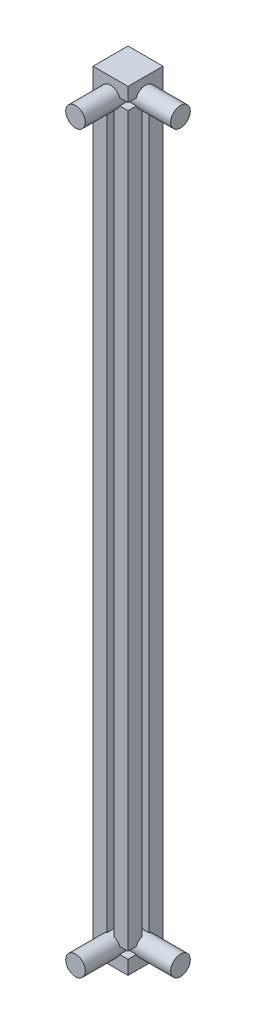
from build123d import *

# Parameters (mm, degrees)
CROQUIS2_W                   = 220
CROQUIS2_H                   = 220
CROQUIS2_W_2                 = 200
CROQUIS2_H_2                 = 200
SALIENTE_EXTRUIR1_DEPTH      = 10
CROQUIS3_W                   = 212
CROQUIS3_H                   = 212
CROQUIS3_W_2                 = 210
CROQUIS3_H_2                 = 210
CROQUIS3_W_3                 = 208
CROQUIS3_H_3                 = 208
CORTAR_EXTRUIR1_DEPTH        = 3.5
CROQUIS4_W                   = 10
CROQUIS4_H                   = 10
SALIENTE_EXTRUIR2_DEPTH      = 200
SALIENTE_EXTRUIR2_DEPTH_BACK = 10
CROQUIS6_W                   = 3.5
CROQUIS6_H                   = 2
CROQUIS6_W_2                 = 2
CROQUIS6_H_2                 = 3.5
CROQUIS6_W_3                 = 1.99805467
CORTAR_EXTRUIR2_DEPTH        = 203.5
CROQUIS7_W                   = 220
CROQUIS7_H                   = 220
CROQUIS7_W_2                 = 200
CROQUIS7_H_2                 = 200
SALIENTE_EXTRUIR3_DEPTH      = 10
CORTAR_EXTRUIR3_START        = -3.5
CROQUIS8_W                   = 207
CROQUIS8_H                   = 2
CORTAR_EXTRUIR3_DEPTH        = 207
MATRIZC1_COUNT               = 4
CROQUIS9_W                   = 86
CROQUIS9_H                   = 16
BRAZOS_DEPTH                 = 10
MATRIZC2_COUNT               = 4
CROQUIS10_W                  = 237.555255491
CROQUIS10_H                  = 247.362549521
CORTAR_EXTRUIR4_DEPTH        = 221
CROQUIS11_W                  = 253.49457107
CROQUIS11_H                  = 258.277976667
CORTAR_EXTRUIR5_DEPTH        = 11
SALIENTE_EXTRUIR4_START      = -6
CROQUIS12_R                  = 2.8
SALIENTE_EXTRUIR4_DEPTH      = 16
CROQUIS13_R                  = 2.8
SALIENTE_EXTRUIR5_DEPTH      = 10
SALIENTE_EXTRUIR5_DEPTH_BACK = 10


with BuildPart() as part:
    # Croquis2 → Saliente-Extruir1 (new body)
    with BuildSketch(Plane.XY):
        with Locations((110, -110)):
            Rectangle(CROQUIS2_W, CROQUIS2_H)
        with Locations((110, -110)):
            Rectangle(CROQUIS2_W_2, CROQUIS2_H_2, mode=Mode.SUBTRACT)
    extrude(amount=SALIENTE_EXTRUIR1_DEPTH)

    # Croquis3 → Cortar-Extruir1 (cut)
    with BuildSketch(Plane.XY.offset(10)):
        with Locations((110, -110)):
            Rectangle(CROQUIS3_W, CROQUIS3_H)
        with Locations((110, -110)):
            Rectangle(CROQUIS3_W_2, CROQUIS3_H_2, mode=Mode.SUBTRACT)
        with Locations((110, -110)):
            Rectangle(CROQUIS3_W_2, CROQUIS3_H_2)
        with Locations((110, -110)):
            Rectangle(CROQUIS3_W_3, CROQUIS3_H_3, mode=Mode.SUBTRACT)
    extrude(amount=-CORTAR_EXTRUIR1_DEPTH, mode=Mode.SUBTRACT)

    # Croquis4 → Saliente-Extruir2 (add, two sides)
    with BuildSketch(Plane.XY.offset(10)) as saliente_extruir2_sk:
        with Locations((5, -5)):
            Rectangle(CROQUIS4_W, CROQUIS4_H)
        with Locations((215, -5)):
            Rectangle(CROQUIS4_W, CROQUIS4_H)
        with Locations((215, -215)):
            Rectangle(CROQUIS4_W, CROQUIS4_H)
        with Locations((5, -215)):
            Rectangle(CROQUIS4_W, CROQUIS4_H)
    extrude(amount=SALIENTE_EXTRUIR2_DEPTH)
    extrude(saliente_extruir2_sk.sketch, amount=-SALIENTE_EXTRUIR2_DEPTH_BACK)

    # Croquis6 → Cortar-Extruir2 (cut)
    with BuildSketch(Plane.XY.offset(210)):
        with Locations((8.25, -5)):
            Rectangle(CROQUIS6_W, CROQUIS6_H)
        with Locations((5, -8.25)):
            Rectangle(CROQUIS6_W_2, CROQUIS6_H_2)
        with Locations((211.75, -5)):
            Rectangle(CROQUIS6_W, CROQUIS6_H)
        with Locations((215, -8.25)):
            Rectangle(CROQUIS6_W_2, CROQUIS6_H_2)
        with Locations((211.75, -215)):
            Rectangle(CROQUIS6_W, CROQUIS6_H)
        with Locations((215.000972665, -211.75)):
            Rectangle(CROQUIS6_W_3, CROQUIS6_H_2)
        with Locations((5, -211.75)):
            Rectangle(CROQUIS6_W_2, CROQUIS6_H_2)
        with Locations((8.25, -215)):
            Rectangle(CROQUIS6_W, CROQUIS6_H)
    extrude(amount=-CORTAR_EXTRUIR2_DEPTH, mode=Mode.SUBTRACT)

    # Croquis7 → Saliente-Extruir3 (add)
    with BuildSketch(Plane.XY.offset(210)):
        with Locations((110, -110)):
            Rectangle(CROQUIS7_W, CROQUIS7_H)
        with Locations((110, -110)):
            Rectangle(CROQUIS7_W_2, CROQUIS7_H_2, mode=Mode.SUBTRACT)
    extrude(amount=SALIENTE_EXTRUIR3_DEPTH)

    # Croquis8 → Cortar-Extruir3 (cut)
    with BuildSketch(Plane(origin=(0, -210, 0), x_dir=(1, 0, 0), z_dir=(0, 1, 0)).offset(CORTAR_EXTRUIR3_START)):
        with Locations((110, -215)):
            Rectangle(CROQUIS8_W, CROQUIS8_H)
    cortar_extruir3 = extrude(amount=CORTAR_EXTRUIR3_DEPTH, mode=Mode.SUBTRACT)

    # MatrizC1: Cortar-Extruir3 ×4 about axis
    matrizc1_axis = Axis((0, -110, 110), (1, 0, 0))
    for i in range(1, MATRIZC1_COUNT):
        add(cortar_extruir3.rotate(matrizc1_axis, i * 360 / MATRIZC1_COUNT), mode=Mode.SUBTRACT)

    # Croquis9 → Brazos (add)
    with BuildSketch(Plane.XY.offset(220)):
        with Locations((43, -110)):
            Rectangle(CROQUIS9_W, CROQUIS9_H)
        with BuildLine():
            ThreePointArc((71.801526277, -112.25), (69.551526277, -110), (71.801526277, -107.75))
            Line((71.801526277, -107.75), (75, -107.75))
            ThreePointArc((75, -107.75), (77.25, -110), (75, -112.25))
            Line((75, -112.25), (71.801526277, -112.25))
        make_face(mode=Mode.SUBTRACT)
        with Locations((177, -110)):
            Rectangle(CROQUIS9_W, CROQUIS9_H)
        with BuildLine():
            Line((145, -107.75), (148.198473723, -107.75))
            ThreePointArc((148.198473723, -107.75), (150.448473723, -110), (148.198473723, -112.25))
            Line((148.198473723, -112.25), (145, -112.25))
            ThreePointArc((145, -112.25), (142.75, -110), (145, -107.75))
        make_face(mode=Mode.SUBTRACT)
    extrude(amount=-BRAZOS_DEPTH)

    # MatrizC2: Cortar-Extruir3 ×4 about axis
    matrizc2_axis = Axis((110, 0, 110), (0, 1, 0))
    for i in range(1, MATRIZC2_COUNT):
        add(cortar_extruir3.rotate(matrizc2_axis, i * 360 / MATRIZC2_COUNT), mode=Mode.SUBTRACT)

    # Croquis10 → Cortar-Extruir4 (cut, through all)
    with BuildSketch(Plane.ZY):
        with Locations((128.777627746, -111.472396129)):
            Rectangle(CROQUIS10_W, CROQUIS10_H)
    extrude(amount=-CORTAR_EXTRUIR4_DEPTH, mode=Mode.SUBTRACT)

    # Croquis11 → Cortar-Extruir5 (cut, through all)
    with BuildSketch(Plane.XY.offset(10)):
        with Locations((136.747285535, -106.715640527)):
            Rectangle(CROQUIS11_W, CROQUIS11_H)
    extrude(amount=-CORTAR_EXTRUIR5_DEPTH, mode=Mode.SUBTRACT)

    # Croquis12 → Saliente-Extruir4 (add)
    with BuildSketch(Plane.XY.offset(10).offset(SALIENTE_EXTRUIR4_START)):
        with Locations((5, -5)):
            Circle(CROQUIS12_R)
        with Locations((5, -215)):
            Circle(CROQUIS12_R)
    extrude(amount=SALIENTE_EXTRUIR4_DEPTH)

    # Croquis13 → Saliente-Extruir5 (add, two sides)
    with BuildSketch(Plane(origin=(10, 0, 0), x_dir=(0, 0, -1), z_dir=(1, 0, 0))) as saliente_extruir5_sk:
        with Locations((-5, -5)):
            Circle(CROQUIS13_R)
        with Locations((-5, -215)):
            Circle(CROQUIS13_R)
    extrude(amount=SALIENTE_EXTRUIR5_DEPTH)
    extrude(saliente_extruir5_sk.sketch, amount=-SALIENTE_EXTRUIR5_DEPTH_BACK)


solid = part.part
